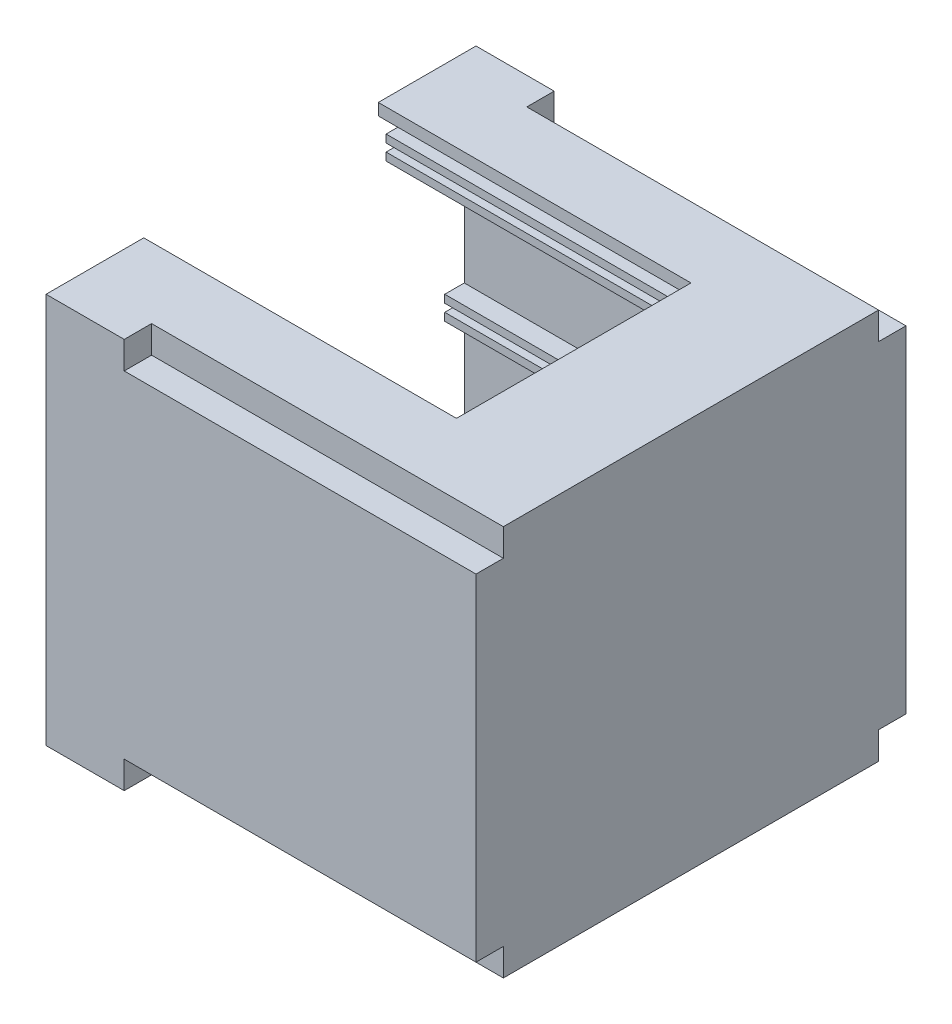
from build123d import *

# Parameters (mm, degrees)
SKETCH2_W           = 110
SKETCH2_H           = 110
BOSS_EXTRUDE1_DEPTH = 100
SKETCH3_W           = 104
SKETCH3_H           = 94
CUT_EXTRUDE1_DEPTH  = 107
SKETCH4_W           = 80
SKETCH4_H           = 60
CUT_EXTRUDE2_DEPTH  = 10
SKETCH5_W           = 20
SKETCH5_H           = 6
BOSS_EXTRUDE2_DEPTH = 107
SKETCH6_W           = 5
SKETCH6_H           = 2
CUT_EXTRUDE3_DEPTH  = 107
SKETCH7_W           = 25
SKETCH7_H           = 6
SKETCH7_W_2         = 5
BOSS_EXTRUDE3_DEPTH = 107
SKETCH8_W           = 5
SKETCH8_H           = 2
CUT_EXTRUDE4_DEPTH  = 107
SKETCH9_W           = 10
SKETCH9_H           = 10
BOSS_EXTRUDE4_DEPTH = 110
SKETCH11_W          = 7
SKETCH11_H          = 7
CUT_EXTRUDE5_DEPTH  = 90
SKETCH13_R          = 1.5
CUT_EXTRUDE6_DEPTH  = 19


with BuildPart() as part:
    # Sketch2 → Boss-Extrude1 (new body)
    with BuildSketch(Plane(origin=(0, 0, 0), x_dir=(1, 0, 0), z_dir=(0, 1, 0))):
        with Locations((55, 55)):
            Rectangle(SKETCH2_W, SKETCH2_H)
    extrude(amount=BOSS_EXTRUDE1_DEPTH)

    # Sketch3 → Cut-Extrude1 (cut)
    with BuildSketch(Plane.ZY):
        with Locations((-55, 50)):
            Rectangle(SKETCH3_W, SKETCH3_H)
    extrude(amount=-CUT_EXTRUDE1_DEPTH, mode=Mode.SUBTRACT)

    # Sketch4 → Cut-Extrude2 (cut)
    with BuildSketch(Plane(origin=(0, 100, 0), x_dir=(1, 0, 0), z_dir=(0, 1, 0))):
        with Locations((40, 55)):
            Rectangle(SKETCH4_W, SKETCH4_H)
    extrude(amount=-CUT_EXTRUDE2_DEPTH, mode=Mode.SUBTRACT)

    # Sketch5 → Boss-Extrude2 (add)
    with BuildSketch(Plane.ZY.offset(-107)):
        with Locations((-97, 89)):
            Rectangle(SKETCH5_W, SKETCH5_H)
        with Locations((-13, 89)):
            Rectangle(SKETCH5_W, SKETCH5_H)
    extrude(amount=BOSS_EXTRUDE2_DEPTH)

    # Sketch6 → Cut-Extrude3 (cut)
    with BuildSketch(Plane.ZY):
        with Locations((-89.5, 89)):
            Rectangle(SKETCH6_W, SKETCH6_H)
        with Locations((-20.5, 89)):
            Rectangle(SKETCH6_W, SKETCH6_H)
    extrude(amount=-CUT_EXTRUDE3_DEPTH, mode=Mode.SUBTRACT)

    # Sketch7 → Boss-Extrude3 (add)
    with BuildSketch(Plane.ZY.offset(-107)):
        with Locations((-94.5, 11)):
            Rectangle(SKETCH7_W, SKETCH7_H)
        with Locations((-15.5, 11)):
            Rectangle(SKETCH7_W, SKETCH7_H)
        with Locations((-104.5, 46)):
            Rectangle(SKETCH7_W_2, SKETCH7_H)
        with Locations((-5.5, 46)):
            Rectangle(SKETCH7_W_2, SKETCH7_H)
    extrude(amount=BOSS_EXTRUDE3_DEPTH)

    # Sketch8 → Cut-Extrude4 (cut)
    with BuildSketch(Plane.ZY):
        with Locations((-5.5, 46)):
            Rectangle(SKETCH8_W, SKETCH8_H)
        with Locations((-84.5, 11)):
            Rectangle(SKETCH8_W, SKETCH8_H)
        with Locations((-25.5, 11)):
            Rectangle(SKETCH8_W, SKETCH8_H)
        with Locations((-104.5, 46)):
            Rectangle(SKETCH8_W, SKETCH8_H)
    extrude(amount=-CUT_EXTRUDE4_DEPTH, mode=Mode.SUBTRACT)

    # Sketch9 → Boss-Extrude4 (add)
    with BuildSketch(Plane(origin=(110, 0, 0), x_dir=(0, 0, -1), z_dir=(1, 0, 0))):
        with Locations((5, 5)):
            Rectangle(SKETCH9_W, SKETCH9_H)
        with Locations((105, 5)):
            Rectangle(SKETCH9_W, SKETCH9_H)
        with Locations((105, 95)):
            Rectangle(SKETCH9_W, SKETCH9_H)
        with Locations((5, 95)):
            Rectangle(SKETCH9_W, SKETCH9_H)
    extrude(amount=-BOSS_EXTRUDE4_DEPTH)

    # Sketch11 → Cut-Extrude5 (cut)
    with BuildSketch(Plane(origin=(110, 0, 0), x_dir=(0, 0, -1), z_dir=(1, 0, 0))):
        with Locations((3.5, 96.5)):
            Rectangle(SKETCH11_W, SKETCH11_H)
        with Locations((106.5, 96.5)):
            Rectangle(SKETCH11_W, SKETCH11_H)
        with Locations((3.5, 3.5)):
            Rectangle(SKETCH11_W, SKETCH11_H)
        with Locations((106.5, 3.5)):
            Rectangle(SKETCH11_W, SKETCH11_H)
    extrude(amount=-CUT_EXTRUDE5_DEPTH, mode=Mode.SUBTRACT)

    # Sketch13 → Cut-Extrude6 (cut)
    with BuildSketch(Plane.ZY):
        with Locations((-106.5, 3.5)):
            Circle(SKETCH13_R)
        with Locations((-3.5, 96.5)):
            Circle(SKETCH13_R)
        with Locations((-106.5, 96.5)):
            Circle(SKETCH13_R)
        with Locations((-3.5, 3.5)):
            Circle(SKETCH13_R)
    extrude(amount=-CUT_EXTRUDE6_DEPTH, mode=Mode.SUBTRACT)


solid = part.part
